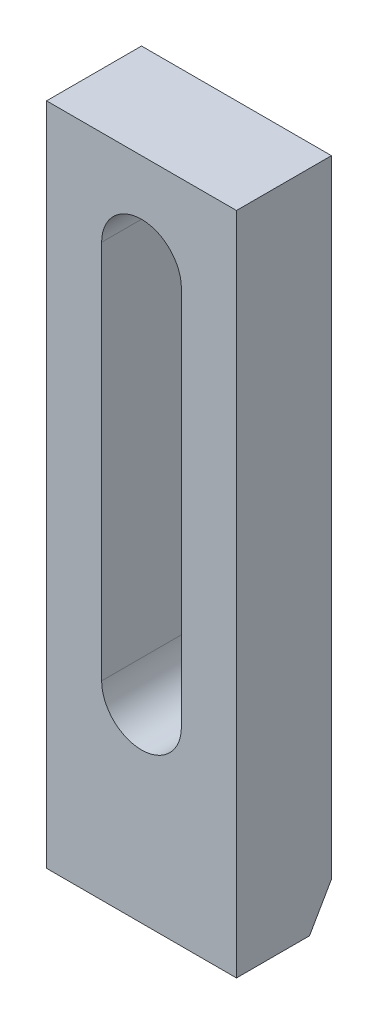
from build123d import *

# Parameters (mm, degrees)
SKETCH_1_W          = 50
SKETCH_1_H          = 175
EXTRUDE_1_DEPTH     = 25
CUT_EXTRUDE_1_DEPTH = 26
CHAMFER_1_SIZE      = 10
CHAMFER_1_SIZE2     = 5.773502692


with BuildPart() as part:
    # Эскиз1 → Бобышка-Вытянуть1 (new body)
    with BuildSketch(Plane.XY):
        with Locations((25, 87.5)):
            Rectangle(SKETCH_1_W, SKETCH_1_H)
    extrude(amount=EXTRUDE_1_DEPTH)

    # Эскиз2 → Вырез-Вытянуть1 (cut, through all)
    with BuildSketch(Plane.XY.offset(25)):
        with BuildLine():
            Line((14.5, 50), (14.5, 150))
            ThreePointArc((14.5, 150), (25, 160.5), (35.5, 150))
            Line((35.5, 150), (35.5, 50))
            ThreePointArc((35.5, 50), (25, 39.5), (14.5, 50))
        make_face()
    extrude(amount=-CUT_EXTRUDE_1_DEPTH, mode=Mode.SUBTRACT)

    # Фаска1
    chamfer_1_edges = [part.edges().sort_by_distance(p)[0] for p in [
        (25, 0, 0),
    ]]
    chamfer_1_side = [part.faces().sort_by_distance(p)[0] for p in [
        (25, 1.820027472, 0),
    ]]
    chamfer(chamfer_1_edges, length=CHAMFER_1_SIZE, length2=CHAMFER_1_SIZE2, reference=chamfer_1_side[0])


solid = part.part
